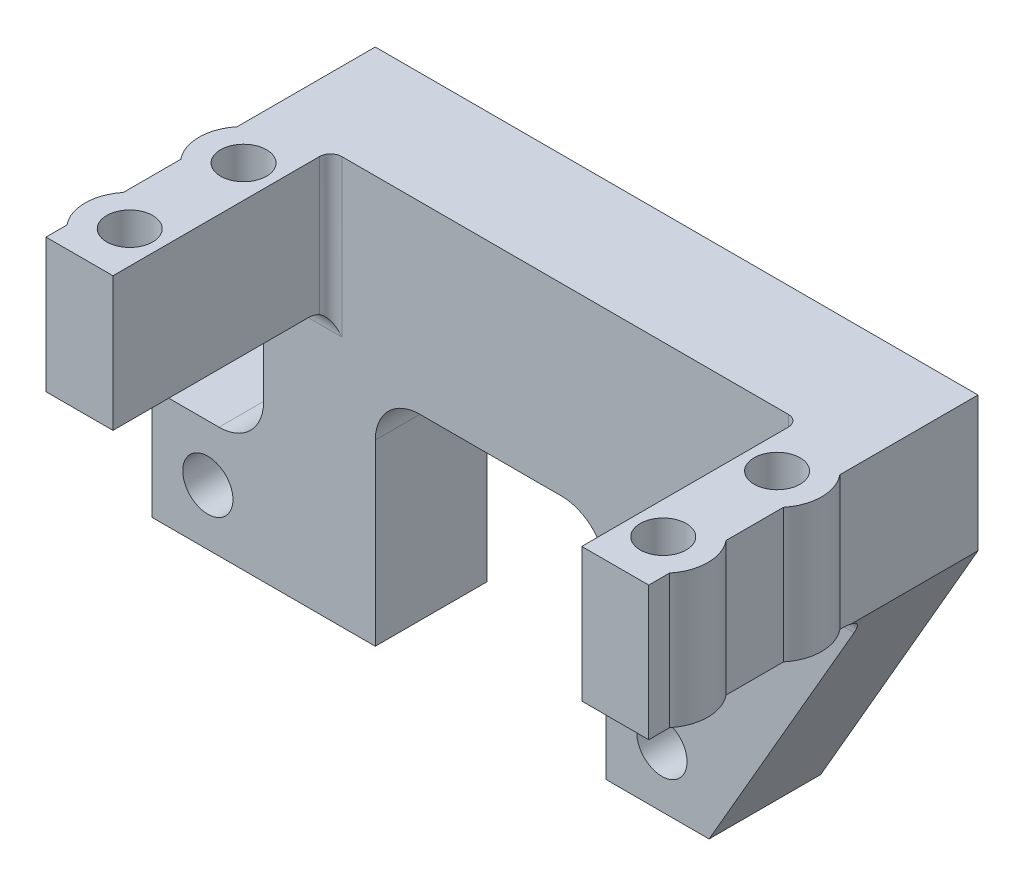
from build123d import *

# Parameters (mm, degrees)
SKETCH1_W            = 54
SKETCH1_H            = 26.5
BOSS_EXTRUDE1_DEPTH  = 10
CUT_EXTRUDE1_DEPTH   = 10
SKETCH3_W            = 15
SKETCH3_H            = 10
SKETCH3_W_2          = 10
BOSS_EXTRUDE2_DEPTH  = 10
CUT_EXTRUDE2_DEPTH   = 10
SKETCH5_W            = 20.679801083
SKETCH5_H            = 5
CUT_EXTRUDE3_DEPTH   = 10
SKETCH6_W            = 6
SKETCH6_H            = 12
BOSS_EXTRUDE3_DEPTH  = 19.5
SKETCH7_R            = 2.06
CUT_EXTRUDE4_DEPTH   = 37.5
SKETCH8_R            = 2.06
BOSS_EXTRUDE4_DEPTH  = 12
FILLET1_R            = 2
FILLET2_R            = 1
FILLET1_OF_MIRROR1_R = 2
FILLET2_OF_MIRROR1_R = 1
SKETCH9_R            = 2.25
CUT_EXTRUDE5_DEPTH   = 10
CUT_EXTRUDE6_DEPTH   = 10
SKETCH11_W           = 20.679801083
SKETCH11_H           = 10
CUT_EXTRUDE7_DEPTH   = 10
FILLET3_R            = 4
SKETCH12_W           = 10
SKETCH12_H           = 10
BOSS_EXTRUDE5_DEPTH  = 10
SKETCH13_R           = 2.25
CUT_EXTRUDE8_DEPTH   = 10
FILLET4_R            = 4


with BuildPart() as part:
    # Sketch1 → Boss-Extrude1 (new body)
    with BuildSketch(Plane.XY):
        Rectangle(SKETCH1_W, SKETCH1_H)
    boss_extrude1 = extrude(amount=BOSS_EXTRUDE1_DEPTH)

    # Sketch2 → Cut-Extrude1 (cut)
    with BuildSketch(Plane(origin=(0, 0, 0), x_dir=(-1, 0, 0), z_dir=(0, 0, -1))):
        Polygon((-27, 1.161007253), (-18.679801083, -13.25), (-27, -13.25), align=None)
    extrude(amount=-CUT_EXTRUDE1_DEPTH, mode=Mode.SUBTRACT)

    # Sketch3 → Boss-Extrude2 (add)
    with BuildSketch(Plane.XZ.offset(13.25)):
        with Locations((11.179801083, 5)):
            Rectangle(SKETCH3_W, SKETCH3_H)
        with Locations((-22, 5)):
            Rectangle(SKETCH3_W_2, SKETCH3_H)
    extrude(amount=BOSS_EXTRUDE2_DEPTH)

    # Sketch4 → Cut-Extrude2 (cut)
    with BuildSketch(Plane(origin=(0, 0, 0), x_dir=(-1, 0, 0), z_dir=(0, 0, -1))):
        Polygon((-18.679801083, -13.25), (-12.906298391, -23.25), (-18.679801083, -23.25), align=None)
    extrude(amount=-CUT_EXTRUDE2_DEPTH, mode=Mode.SUBTRACT)

    # Sketch5 → Cut-Extrude3 (cut)
    with BuildSketch(Plane(origin=(0, 0, 0), x_dir=(-1, 0, 0), z_dir=(0, 0, -1))):
        with Locations((6.660099458, -10.75)):
            Rectangle(SKETCH5_W, SKETCH5_H)
    extrude(amount=-CUT_EXTRUDE3_DEPTH, mode=Mode.SUBTRACT)

    # Sketch6 → Boss-Extrude3 (add)
    with BuildSketch(Plane.XY.offset(10)):
        with Locations((24, 7.25)):
            Rectangle(SKETCH6_W, SKETCH6_H)
    boss_extrude3 = extrude(amount=BOSS_EXTRUDE3_DEPTH)

    # Sketch7 → Cut-Extrude4 (cut, through all)
    with BuildSketch(Plane(origin=(0, 13.25, 0), x_dir=(1, 0, 0), z_dir=(0, 1, 0))):
        with Locations((23.9, -25.1)):
            Circle(SKETCH7_R)
        with Locations((23.9, -14.9)):
            Circle(SKETCH7_R)
    cut_extrude4 = extrude(amount=-CUT_EXTRUDE4_DEPTH, mode=Mode.SUBTRACT)

    # Sketch8 → Boss-Extrude4 (add)
    with BuildSketch(Plane(origin=(0, 13.25, 0), x_dir=(1, 0, 0), z_dir=(0, 1, 0))):
        with BuildLine():
            Line((21, -27.854995463), (21, -22.345004537))
            ThreePointArc((21, -22.345004537), (27.9, -25.1), (21, -27.854995463))
        make_face()
        with Locations((23.9, -25.1)):
            Circle(SKETCH8_R, mode=Mode.SUBTRACT)
        with BuildLine():
            Line((21, -17.654995463), (21, -12.145004537))
            ThreePointArc((21, -12.145004537), (27.9, -14.9), (21, -17.654995463))
        make_face()
        with Locations((23.9, -14.9)):
            Circle(SKETCH8_R, mode=Mode.SUBTRACT)
    boss_extrude4 = extrude(amount=-BOSS_EXTRUDE4_DEPTH)

    # Fillet1
    fillet1_edges = [part.edges().sort_by_distance(p)[0] for p in [
        (24, 1.25, 10),
    ]]
    fillet(fillet1_edges, radius=FILLET1_R)

    # Fillet2
    fillet2_edges = [part.edges().sort_by_distance(p)[0] for p in [
        (21, 7.25, 10),
    ]]
    fillet(fillet2_edges, radius=FILLET2_R)

    # Mirror1: Boss-Extrude1, Boss-Extrude3, Cut-Extrude4, Boss-Extrude4 across plane
    add(boss_extrude1.mirror(Plane(origin=(0, 0, 0), x_dir=(0, 0, 1), z_dir=(1, 0, 0))))
    add(boss_extrude3.mirror(Plane(origin=(0, 0, 0), x_dir=(0, 0, 1), z_dir=(1, 0, 0))))
    add(cut_extrude4.mirror(Plane(origin=(0, 0, 0), x_dir=(0, 0, 1), z_dir=(1, 0, 0))), mode=Mode.SUBTRACT)
    add(boss_extrude4.mirror(Plane(origin=(0, 0, 0), x_dir=(0, 0, 1), z_dir=(1, 0, 0))))

    # Fillet1 of Mirror1
    fillet1_of_mirror1_edges = [part.edges().sort_by_distance(p)[0] for p in [
        (-24, 1.25, 10),
    ]]
    fillet(fillet1_of_mirror1_edges, radius=FILLET1_OF_MIRROR1_R)

    # Fillet2 of Mirror1
    fillet2_of_mirror1_edges = [part.edges().sort_by_distance(p)[0] for p in [
        (-21, 7.25, 10),
    ]]
    fillet(fillet2_of_mirror1_edges, radius=FILLET2_OF_MIRROR1_R)

    # Sketch9 → Cut-Extrude5 (cut)
    with BuildSketch(Plane.XY.offset(10)):
        with Locations((8.679801083, -18.25)):
            Circle(SKETCH9_R)
    extrude(amount=-CUT_EXTRUDE5_DEPTH, mode=Mode.SUBTRACT)

    # Sketch10 → Cut-Extrude6 (cut)
    with BuildSketch(Plane(origin=(0, 0, 0), x_dir=(-1, 0, 0), z_dir=(0, 0, -1))):
        Polygon((-27, 1.161007253), (-18.679801083, -13.25), (-27, -13.25), align=None)
    extrude(amount=-CUT_EXTRUDE6_DEPTH, mode=Mode.SUBTRACT)

    # Sketch11 → Cut-Extrude7 (cut)
    with BuildSketch(Plane(origin=(0, 0, 0), x_dir=(-1, 0, 0), z_dir=(0, 0, -1))):
        with Locations((6.660099458, -8.25)):
            Rectangle(SKETCH11_W, SKETCH11_H)
    extrude(amount=-CUT_EXTRUDE7_DEPTH, mode=Mode.SUBTRACT)

    # Fillet3
    fillet3_edges = [part.edges().sort_by_distance(p)[0] for p in [
        (-17, -3.25, 5),
        (3.679801083, -3.25, 5),
    ]]
    fillet(fillet3_edges, radius=FILLET3_R)

    # Sketch12 → Boss-Extrude5 (add)
    with BuildSketch(Plane.XY.offset(10)):
        with Locations((-32, -18.25)):
            Rectangle(SKETCH12_W, SKETCH12_H)
    extrude(amount=-BOSS_EXTRUDE5_DEPTH)

    # Sketch13 → Cut-Extrude8 (cut)
    with BuildSketch(Plane.XY.offset(10)):
        with Locations((-32, -18.25)):
            Circle(SKETCH13_R)
    extrude(amount=-CUT_EXTRUDE8_DEPTH, mode=Mode.SUBTRACT)

    # Fillet4
    fillet4_edges = [part.edges().sort_by_distance(p)[0] for p in [
        (-27, -13.25, 5),
    ]]
    fillet(fillet4_edges, radius=FILLET4_R)


solid = part.part
